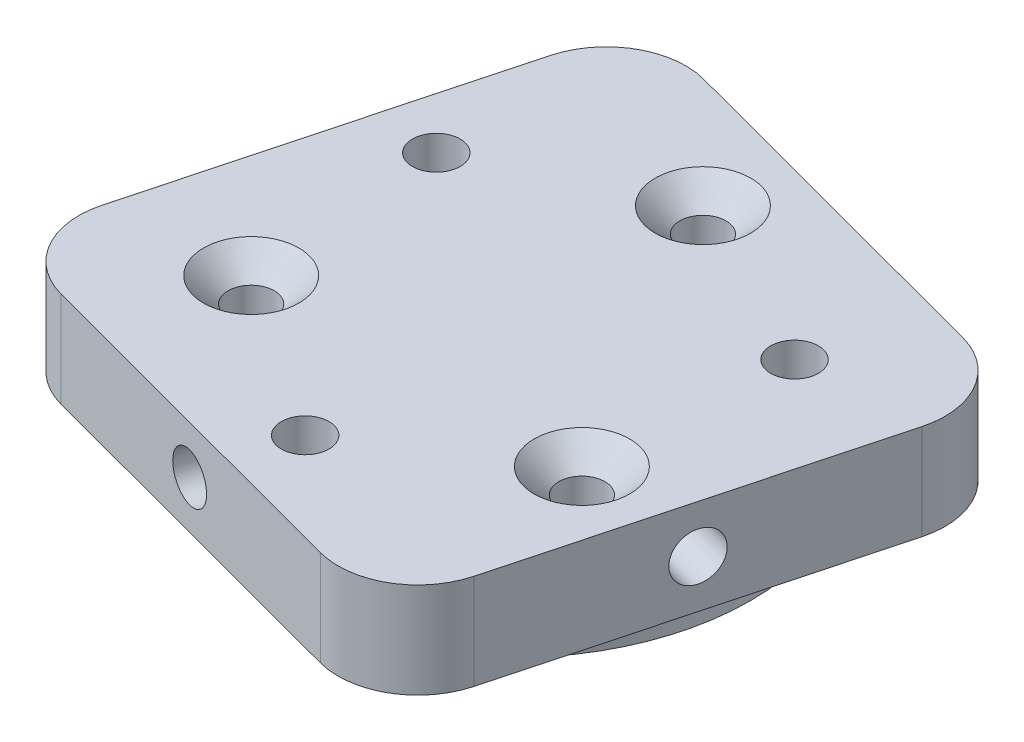
from build123d import *

# Parameters (mm, degrees)
SKETCH_1_R          = 15
SKETCH_1_R_2        = 1.45
SKETCH_1_R_3        = 1.5
EXTRUDE_1_DEPTH     = 8
SKETCH_2_R          = 1.45
SKETCH_2_R_2        = 1.5
EXTRUDE_2_DEPTH     = 6
CHAMFER_1_SIZE      = 1.55
SKETCH_3_R          = 1.5
CUT_EXTRUDE_1_DEPTH = 40.846349976
SKETCH_4_R          = 1.5
CUT_EXTRUDE_2_DEPTH = 40.846349976


with BuildPart() as part:
    # 草图1 → 凸台-拉伸1 (new body)
    with BuildSketch(Plane(origin=(0, 0, 0), x_dir=(1, 0, 0), z_dir=(0, 1, 0))):
        Circle(SKETCH_1_R)
        with Locations((0, 12)):
            Circle(SKETCH_1_R_2, mode=Mode.SUBTRACT)
        with Locations((-10.392304845, -6)):
            Circle(SKETCH_1_R_2, mode=Mode.SUBTRACT)
        with Locations((10.392304845, -6)):
            Circle(SKETCH_1_R_2, mode=Mode.SUBTRACT)
        with Locations((-11.258330249, 6.5)):
            Circle(SKETCH_1_R_3, mode=Mode.SUBTRACT)
        with Locations((0, -13)):
            Circle(SKETCH_1_R_3, mode=Mode.SUBTRACT)
        with Locations((11.258330249, 6.5)):
            Circle(SKETCH_1_R_3, mode=Mode.SUBTRACT)
    extrude(amount=EXTRUDE_1_DEPTH)

    # 草图2 → 凸台-拉伸2 (add)
    with BuildSketch(Plane(origin=(0, 8, 0), x_dir=(1, 0, 0), z_dir=(0, 1, 0))):
        with BuildLine():
            Line((-6.859687774, 18.906207542), (15.363533928, 12.979284466))
            ThreePointArc((15.363533928, 12.979284466), (18.402280708, 10.653197849), (18.906207542, 6.859687774))
            Line((18.906207542, 6.859687774), (12.979284466, -15.363533928))
            ThreePointArc((12.979284466, -15.363533928), (10.653197849, -18.402280708), (6.859687774, -18.906207542))
            Line((6.859687774, -18.906207542), (-15.363533928, -12.979284466))
            ThreePointArc((-15.363533928, -12.979284466), (-18.402280708, -10.653197849), (-18.906207542, -6.859687774))
            Line((-18.906207542, -6.859687774), (-12.979284466, 15.363533928))
            ThreePointArc((-12.979284466, 15.363533928), (-10.653197849, 18.402280708), (-6.859687774, 18.906207542))
        make_face()
        with Locations((0, 12)):
            Circle(SKETCH_2_R, mode=Mode.SUBTRACT)
        with Locations((-11.258330249, 6.5)):
            Circle(SKETCH_2_R_2, mode=Mode.SUBTRACT)
        with Locations((11.258330249, 6.5)):
            Circle(SKETCH_2_R_2, mode=Mode.SUBTRACT)
        with Locations((-10.392304845, -6)):
            Circle(SKETCH_2_R, mode=Mode.SUBTRACT)
        with Locations((0, -13)):
            Circle(SKETCH_2_R_2, mode=Mode.SUBTRACT)
        with Locations((10.392304845, -6)):
            Circle(SKETCH_2_R, mode=Mode.SUBTRACT)
    extrude(amount=-EXTRUDE_2_DEPTH)

    # 倒角1
    chamfer_1_edges = [part.edges().sort_by_distance(p)[0] for p in [
        (8.942304845, 8, 6),
        (-1.45, 8, -12),
        (-11.842304845, 8, 6),
    ]]
    chamfer(chamfer_1_edges, length=CHAMFER_1_SIZE)

    # 草图3 → 切除-拉伸1 (cut, through all)
    with BuildSketch(Plane(origin=(-15.942746004, 0, -4.251923077), x_dir=(-0.257692308, 0, 0.966227031), z_dir=(-0.966227031, 0, -0.257692308))):
        with Locations((0, 5)):
            Circle(SKETCH_3_R)
    extrude(amount=-CUT_EXTRUDE_1_DEPTH, mode=Mode.SUBTRACT)

    # 草图4 → 切除-拉伸2 (cut, through all)
    with BuildSketch(Plane(origin=(4.251923077, 0, -15.942746004), x_dir=(-0.966227031, 0, -0.257692308), z_dir=(0.257692308, 0, -0.966227031))):
        with Locations((0.092307692, 5)):
            Circle(SKETCH_4_R)
    extrude(amount=-CUT_EXTRUDE_2_DEPTH, mode=Mode.SUBTRACT)


solid = part.part
